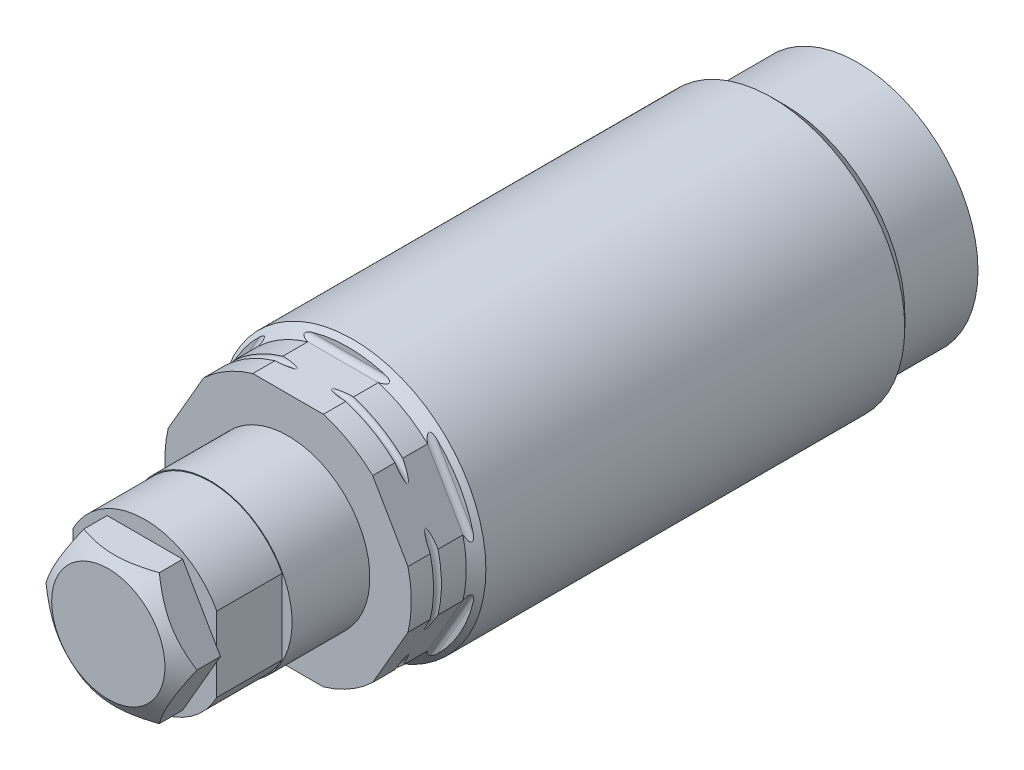
from build123d import *

# Parameters (mm, degrees)
CUT_EXTRUDE1_DEPTH      = 13.9159
CIRPATTERN1_COUNT       = 6
SKETCH3_W               = 13.903
SKETCH3_H               = 7.9375
SKETCH4_R               = 3.0226
CUT_EXTRUDE2_DEPTH      = 8.001
SKETCH10_W              = 0.9652
SKETCH10_H              = 6.35
CUT_EXTRUDE3_DEPTH      = 13.9159001
CUT_EXTRUDE3_DEPTH_BACK = 13.9159001
EXTRUDE2_DEPTH          = 3.556
SKETCH13_W              = 6.35
SKETCH13_H              = 0.0775


with BuildPart() as part:
    # Sketch1 → Revolve1 (revolve)
    with BuildSketch(Plane(origin=(0, 0, 0), x_dir=(0, 0, -1), z_dir=(1, 0, 0)), mode=Mode.PRIVATE) as revolve1_sk:
        Polygon((0, 0), (0, 11.6713), (-7.112, 11.6713), (-8.3566, 12.9159), (-49.0255, 12.9159), (-49.978, 11.9634), (-55.312, 11.9634), (-55.312, 0), align=None)
    revolve(revolve1_sk.sketch.rotate(Axis((0, 0, 0), (0, 0, -1)), 90), axis=Axis((0, 0, 0), (0, 0, -1)))  # turned: the seam where the file's is

    # Sketch2 → Cut-Extrude1 (cut, symmetric)
    with BuildSketch(Plane(origin=(0, 0, 0), x_dir=(0, 0, -1), z_dir=(1, 0, 0))):
        with BuildLine():
            Line((-55.312, 11.46175), (-49.978, 11.46175))
            ThreePointArc((-49.978, 11.46175), (-49.618789755, 11.610539755), (-49.47, 11.96975))
            Line((-49.47, 11.96975), (-49.47, 14.63675))
            Line((-49.47, 14.63675), (-55.312, 14.63675))
            Line((-55.312, 14.63675), (-55.312, 11.46175))
        make_face()
    cut_extrude1 = extrude(amount=CUT_EXTRUDE1_DEPTH, both=True, mode=Mode.SUBTRACT)

    # CirPattern1: Cut-Extrude1 ×6 about axis
    cirpattern1_axis = Axis((0, 0, 0), (0, 0, 1))
    for i in range(1, CIRPATTERN1_COUNT):
        add(cut_extrude1.rotate(cirpattern1_axis, i * 360 / CIRPATTERN1_COUNT), mode=Mode.SUBTRACT)

    # Sketch3 → Revolve2 (revolve)
    with BuildSketch(Plane(origin=(0, 0, 0), x_dir=(0, 0, -1), z_dir=(1, 0, 0)), mode=Mode.PRIVATE) as revolve2_sk:
        with Locations((-62.2635, 3.96875)):
            Rectangle(SKETCH3_W, SKETCH3_H)
    revolve(revolve2_sk.sketch.rotate(Axis((0, 0, 0), (0, 0, 1)), 270), axis=Axis((0, 0, 0), (0, 0, 1)))  # turned: the seam where the file's is

    # Sketch4 → Cut-Extrude2 (cut)
    with BuildSketch(Plane.XY.offset(69.215)):
        Circle(SKETCH4_R)
    extrude(amount=-CUT_EXTRUDE2_DEPTH, mode=Mode.SUBTRACT)

    # Sketch5 → Cut-Revolve1 (revolve, cut)
    with BuildSketch(Plane(origin=(0, 0, 0), x_dir=(0, 0, -1), z_dir=(1, 0, 0)), mode=Mode.PRIVATE) as cut_revolve1_sk:
        with BuildLine():
            Line((-53.153, 15.1384), (-53.153, 11.9634))
            ThreePointArc((-53.153, 11.9634), (-52.772, 11.5824), (-52.391, 11.9634))
            Line((-52.391, 11.9634), (-52.391, 15.1384))
            Line((-52.391, 15.1384), (-53.153, 15.1384))
        make_face()
    revolve(cut_revolve1_sk.sketch.rotate(Axis((0, 0, 0), (0, 0, 1)), 270), axis=Axis((0, 0, 0), (0, 0, 1)), mode=Mode.SUBTRACT)  # turned: the seam where the file's is

    # Sketch10 → Cut-Extrude3 (cut, two sides)
    with BuildSketch(Plane(origin=(0, 0, 0), x_dir=(1, 0, 0), z_dir=(0, 1, 0))) as cut_extrude3_sk:
        with Locations((7.4549, -66.04)):
            Rectangle(SKETCH10_W, SKETCH10_H)
        with Locations((-7.4549, -66.04)):
            Rectangle(SKETCH10_W, SKETCH10_H)
    extrude(amount=CUT_EXTRUDE3_DEPTH, mode=Mode.SUBTRACT)
    extrude(cut_extrude3_sk.sketch, amount=-CUT_EXTRUDE3_DEPTH_BACK, mode=Mode.SUBTRACT)

    # Sketch11 → Extrude2 (add)
    with BuildSketch(Plane.XY.offset(69.215)):
        Polygon((3.666174209, 6.35), (-3.666174209, 6.35), (-7.332348419, 0), (-3.666174209, -6.35), (3.666174209, -6.35), (7.332348419, 0), align=None)
    extrude(amount=EXTRUDE2_DEPTH)

    # Sketch12 → Cut-Revolve3 (revolve, cut)
    with BuildSketch(Plane(origin=(0, 0, 0), x_dir=(1, 0, 0), z_dir=(0, 1, 0)), mode=Mode.PRIVATE) as cut_revolve3_sk:
        Polygon((-7.332348419, -71.487345638), (-7.332348419, -72.771), (-5.4991, -72.771), align=None)
    revolve(cut_revolve3_sk.sketch.rotate(Axis((0, 0, 0), (0, 0, 1)), 180), axis=Axis((0, 0, 0), (0, 0, 1)), mode=Mode.SUBTRACT)  # turned: the seam where the file's is

    # Sketch13 → Cut-Revolve4 (revolve, cut)
    with BuildSketch(Plane(origin=(0, 0, 0), x_dir=(0, 0, -1), z_dir=(1, 0, 0)), mode=Mode.PRIVATE) as cut_revolve4_sk:
        with Locations((-66.04, 7.89875)):
            Rectangle(SKETCH13_W, SKETCH13_H)
    revolve(cut_revolve4_sk.sketch.rotate(Axis((0, 0, 0), (0, 0, 1)), 270), axis=Axis((0, 0, 0), (0, 0, 1)), mode=Mode.SUBTRACT)  # turned: the seam where the file's is


solid = part.part
